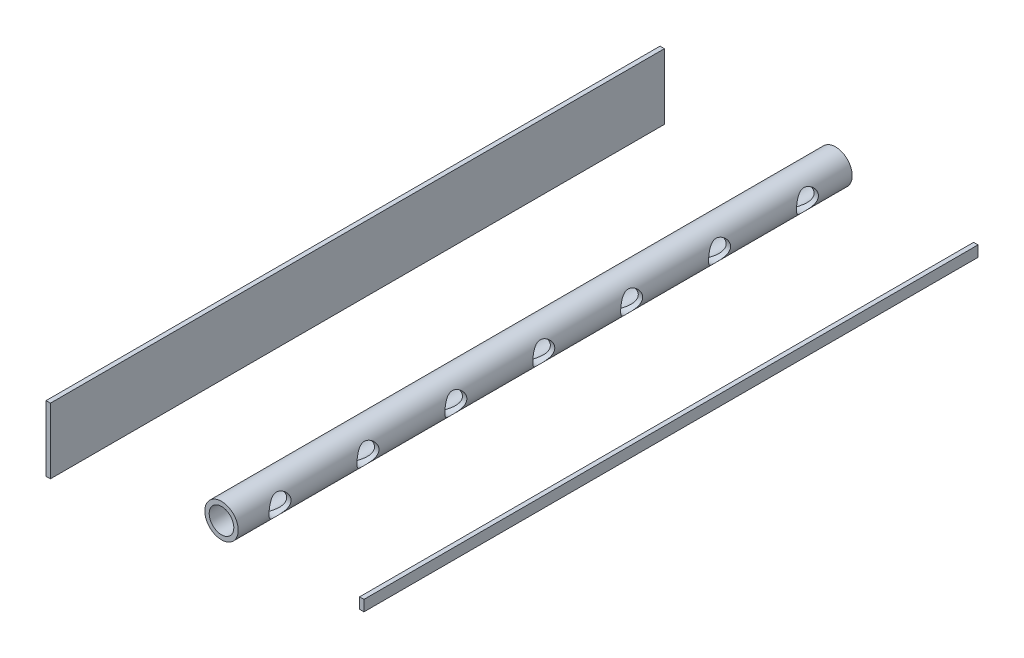
from build123d import *

# Parameters (mm, degrees)
SKETCH1_R             = 7.6
SKETCH1_R_2           = 5.6
BOSS_EXTRUDE1_DEPTH   = 279.4
BOSS_EXTRUDE1_2_DEPTH = 279.4
SKETCH1_W             = 1.99898
SKETCH1_H             = 4.933496123
BOSS_EXTRUDE1_3_DEPTH = 279.4
SKETCH4_R             = 5
CUT_EXTRUDE7_DEPTH    = 76


with BuildPart() as part:
    # Sketch1 → Boss-Extrude1 (new body)
    with BuildSketch(Plane.XY):
        with Locations((-27.053797295, 0.804244933)):
            Circle(SKETCH1_R)
        with Locations((-27.053797295, 0.804244933)):
            Circle(SKETCH1_R_2, mode=Mode.SUBTRACT)
    extrude(amount=BOSS_EXTRUDE1_DEPTH)

    # Sketch4 → Cut-Extrude7 (cut)
    with BuildSketch(Plane(origin=(-84.91182631, 0, 0), x_dir=(0, 0, -1), z_dir=(1, 0, 0))):
        with Locations((-260.350704173, 0.510277917)):
            Circle(SKETCH4_R)
        with Locations((-220.350704173, 0.510277917)):
            Circle(SKETCH4_R)
        with Locations((-180.350704173, 0.510277917)):
            Circle(SKETCH4_R)
        with Locations((-140.350704173, 0.510277917)):
            Circle(SKETCH4_R)
        with Locations((-100.350704173, 0.510277917)):
            Circle(SKETCH4_R)
        with Locations((-60.350704173, 0.510277917)):
            Circle(SKETCH4_R)
        with Locations((-20.350704173, 0.510277917)):
            Circle(SKETCH4_R)
    extrude(amount=CUT_EXTRUDE7_DEPTH, mode=Mode.SUBTRACT)


with BuildPart() as body_2:
    # Sketch1 → Boss-Extrude1 2 (new body)
    with BuildSketch(Plane.XY):
        with BuildLine():
            Line((-106.91080631, 8.159920944), (-104.91182631, 8.159920944))
            Line((-104.91182631, 8.159920944), (-104.91182631, -21.687578189))
            Line((-104.91182631, -21.687578189), (-106.466449759, -21.687578189))
            add(Edge.make_bspline(
                [(-106.91080631, -21.812797109), (-106.762684292, -21.771059347), (-106.614565567, -21.729319539), (-106.466449759, -21.687578189)],
                knots=[0.612716824, 0.612716824, 0.612716824, 0.612716824, 0.613439282, 0.613439282, 0.613439282, 0.613439282], degree=3))
            Line((-106.91080631, -21.812797109), (-106.91080631, -21.687578189))
            Line((-106.91080631, -21.687578189), (-106.91080631, 8.159920944))
        make_face()
    extrude(amount=BOSS_EXTRUDE1_2_DEPTH)


with BuildPart() as body_3:
    # Sketch1 → Boss-Extrude1 3 (new body)
    with BuildSketch(Plane.XY):
        with Locations((36.776002075, -0.284978648)):
            Rectangle(SKETCH1_W, SKETCH1_H)
    extrude(amount=BOSS_EXTRUDE1_3_DEPTH)


solid = Compound([part.part, body_2.part, body_3.part])
